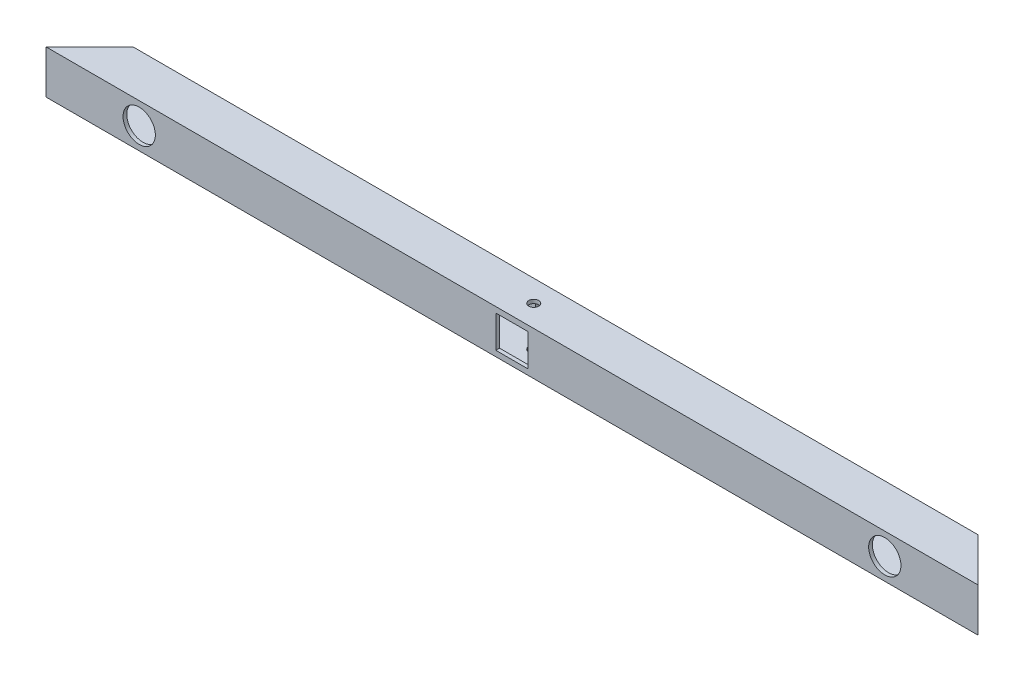
from build123d import *

# Parameters (mm, degrees)
BOSS_EXTRUDE1_DEPTH = 35
SHELL1_T            = -3
SKETCH4_R           = 13
CUT_EXTRUDE1_DEPTH  = 49
SKETCH5_W           = 26
SKETCH5_H           = 26
CUT_EXTRUDE2_DEPTH  = 39
SKETCH6_R           = 4
CUT_EXTRUDE3_DEPTH  = 35


with BuildPart() as part:
    # Sketch1 → Boss-Extrude1 (new body)
    with BuildSketch(Plane(origin=(0, 0, 0), x_dir=(1, 0, 0), z_dir=(0, 1, 0))):
        Polygon((-325, -12.5), (-290, 22.5), (390, 22.5), (425, -12.5), align=None)
    extrude(amount=BOSS_EXTRUDE1_DEPTH)

    # Shell1
    shell1_openings = [part.faces().sort_by_distance(p)[0] for p in [
        (-307.5, 17.5, -5),
        (407.5, 17.5, -5),
    ]]
    offset(amount=SHELL1_T, openings=shell1_openings, kind=Kind.INTERSECTION)

    # Sketch4 → Cut-Extrude1 (cut)
    with BuildSketch(Plane.XY.offset(12.5)):
        with Locations((-250, 17.5)):
            Circle(SKETCH4_R)
        with Locations((350, 17.5)):
            Circle(SKETCH4_R)
    extrude(amount=-CUT_EXTRUDE1_DEPTH, mode=Mode.SUBTRACT)

    # Sketch5 → Cut-Extrude2 (cut)
    with BuildSketch(Plane(origin=(0, 0, -22.5), x_dir=(-1, 0, 0), z_dir=(0, 0, -1))):
        with Locations((-50, 17.5)):
            Rectangle(SKETCH5_W, SKETCH5_H)
    extrude(amount=-CUT_EXTRUDE2_DEPTH, mode=Mode.SUBTRACT)

    # Sketch6 → Cut-Extrude3 (cut)
    with BuildSketch(Plane(origin=(0, 35, 0), x_dir=(1, 0, 0), z_dir=(0, 1, 0))):
        with Locations((50, 5)):
            Circle(SKETCH6_R)
    extrude(amount=-CUT_EXTRUDE3_DEPTH, mode=Mode.SUBTRACT)


solid = part.part
